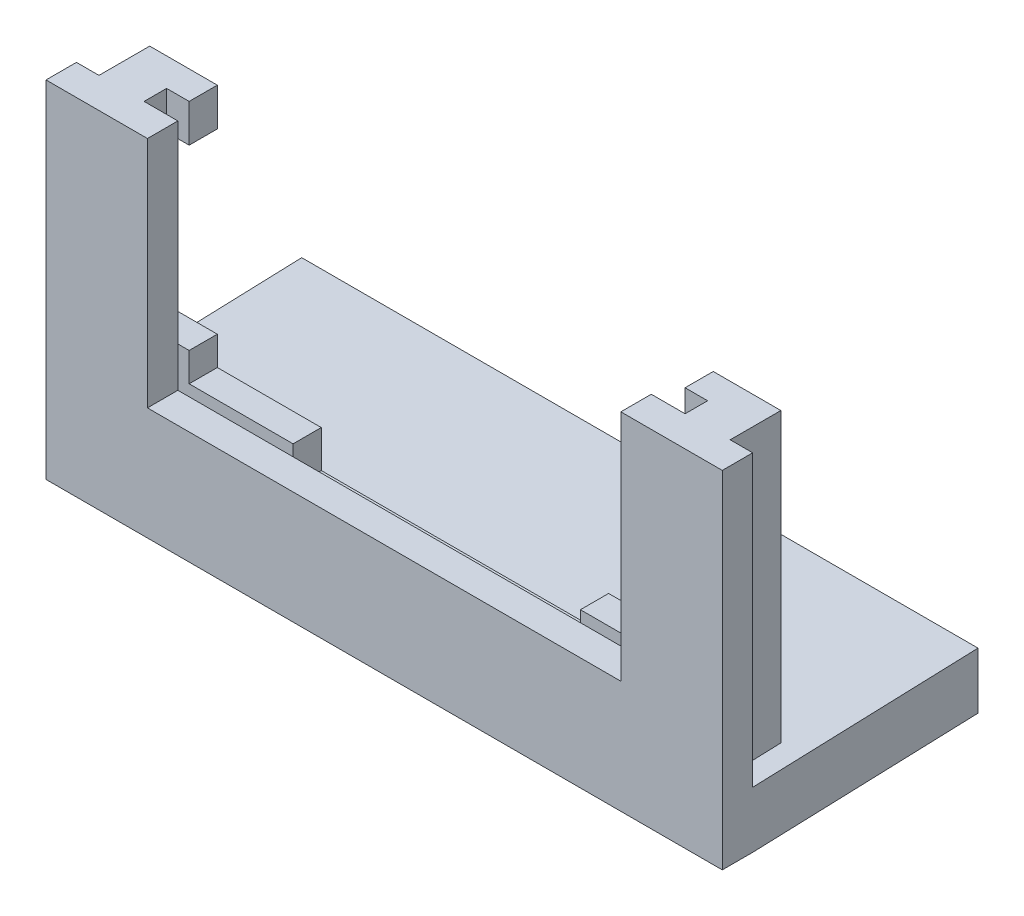
from build123d import *

# Parameters (mm, degrees)
BOSS_EXTRUDE1_DEPTH = 2.7
BOSS_EXTRUDE2_DEPTH = 2
BOSS_EXTRUDE3_DEPTH = 2.5
SKETCH9_W           = 60
SKETCH9_H           = 5
CUT_EXTRUDE6_DEPTH  = 10
SKETCH11_W          = 25.492902138
SKETCH11_H          = 3.302010066
SKETCH11_W_2        = 3.620048782
SKETCH11_H_2        = 15.848017525
SKETCH11_W_3        = 3.810768748
SKETCH11_H_3        = 15.769779212
CUT_EXTRUDE7_DEPTH  = 4.5


with BuildPart() as part:
    # Sketch1 → Boss-Extrude1 (new body)
    with BuildSketch(Plane.XY):
        Polygon((-54.373493976, 36.84753086), (-63.373493976, 36.84753086), (-63.373493976, -23.15246914), (-3.373493976, -23.15246914), (-3.373493976, 36.84753086), (-12.373493976, 36.84753086), (-12.373493976, -13.15246914), (-54.373493976, -13.15246914), align=None)
    extrude(amount=BOSS_EXTRUDE1_DEPTH)

    # Sketch3 → Boss-Extrude2 (add)
    with BuildSketch(Plane(origin=(0, 0, 0), x_dir=(-1, 0, 0), z_dir=(0, 0, -1))):
        Polygon((9.373493976, -16.15246914), (9.373493976, 36.84753086), (5.373493976, 36.84753086), (5.373493976, -20.15246914), (61.373493976, -20.15246914), (61.373493976, 36.84753086), (57.373493976, 36.84753086), (57.373493976, -16.15246914), align=None)
    extrude(amount=BOSS_EXTRUDE2_DEPTH)

    # Sketch4 → Boss-Extrude3 (add)
    with BuildSketch(Plane(origin=(0, 0, -2), x_dir=(-1, 0, 0), z_dir=(0, 0, -1))):
        Polygon((55.373493976, 36.84753086), (55.373493976, -14.15246914), (11.373493976, -14.15246914), (11.373493976, 36.84753086), (5.373493976, 36.84753086), (5.373493976, -20.15246914), (61.373493976, -20.15246914), (61.373493976, 36.84753086), align=None)
    extrude(amount=BOSS_EXTRUDE3_DEPTH)

    # Sweep1: sweep along a curve in space
    with BuildLine() as sweep1_path:
        Line((-33.373493976, -20.65246914, 0), (-33.373493976, -19.954479206, -19.98781654))
    # Sketch9 → Sweep1 (sweep)
    with BuildSketch(Plane(origin=(0, 0, 0), x_dir=(-1, 0, 0), z_dir=(0, 0, -1))):
        with Locations((33.373493976, -20.65246914)):
            Rectangle(SKETCH9_W, SKETCH9_H)
    sweep(path=sweep1_path.line)

    # Sketch10 → Cut-Extrude6 (cut)
    with BuildSketch(Plane(origin=(0, 0, -4.5), x_dir=(-1, 0, 0), z_dir=(0, 0, -1))):
        Polygon((3.373493976, 7.545520794), (63.373493976, 7.545520794), (73.535080065, 7.545520794), (73.535080065, 46.239057039), (-7.104014128, 46.239057039), (-7.104014128, 7.545520794), align=None)
    extrude(amount=-CUT_EXTRUDE6_DEPTH, mode=Mode.SUBTRACT)

    # Sketch11 → Cut-Extrude7 (cut)
    with BuildSketch(Plane(origin=(0, 0, -4.5), x_dir=(-1, 0, 0), z_dir=(0, 0, -1))):
        with Locations((33.405280637, -15.803474173)):
            Rectangle(SKETCH11_W, SKETCH11_H)
        with Locations((9.563469585, -3.743911731)):
            Rectangle(SKETCH11_W_2, SKETCH11_H_2)
        with Locations((57.27887835, -3.704792574)):
            Rectangle(SKETCH11_W_3, SKETCH11_H_3)
    extrude(amount=-CUT_EXTRUDE7_DEPTH, mode=Mode.SUBTRACT)


solid = part.part
